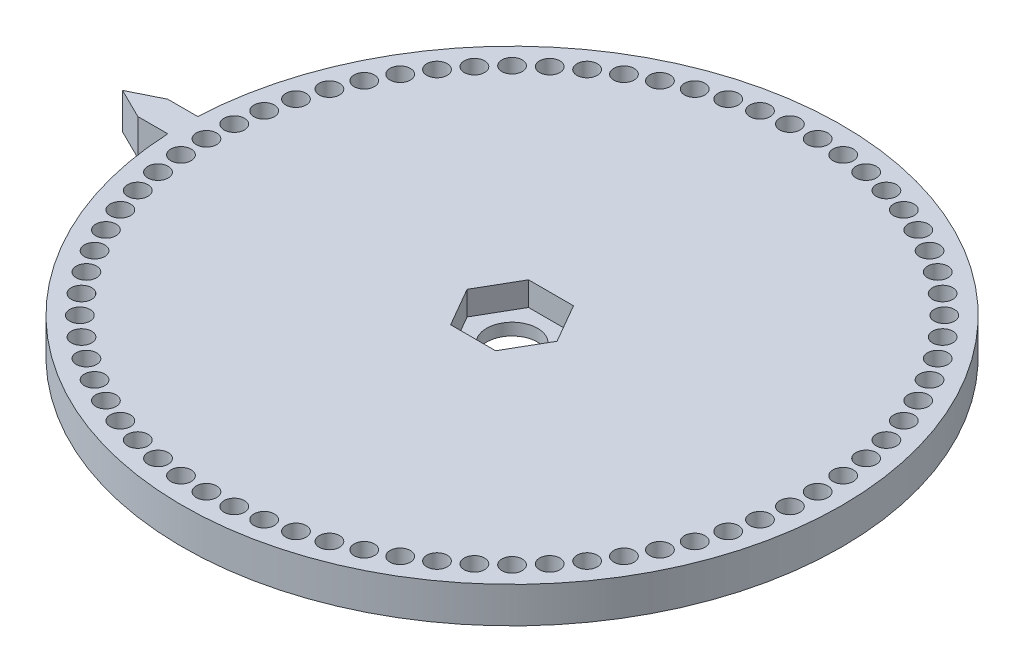
from build123d import *

# Parameters (mm, degrees)
SKETCH1_R           = 55
BOSS_EXTRUDE1_DEPTH = 6
CUT_EXTRUDE1_DEPTH  = 4
SKETCH3_R           = 1.7
CUT_EXTRUDE2_DEPTH  = 7
CIRPATTERN1_COUNT   = 72
SKETCH4_R           = 4.25
CUT_EXTRUDE3_DEPTH  = 3
BOSS_EXTRUDE2_DEPTH = 6


with BuildPart() as part:
    # Sketch1 → Boss-Extrude1 (new body)
    with BuildSketch(Plane(origin=(0, 0, 0), x_dir=(1, 0, 0), z_dir=(0, 1, 0))):
        Circle(SKETCH1_R)
    extrude(amount=BOSS_EXTRUDE1_DEPTH)

    # Sketch2 → Cut-Extrude1 (cut)
    with BuildSketch(Plane(origin=(0, 6, 0), x_dir=(1, 0, 0), z_dir=(0, 1, 0))):
        Polygon((3.75277675, 6.5), (-3.75277675, 6.5), (-7.505553499, 0), (-3.75277675, -6.5), (3.75277675, -6.5), (7.505553499, 0), align=None)
    extrude(amount=-CUT_EXTRUDE1_DEPTH, mode=Mode.SUBTRACT)

    # Sketch3 → Cut-Extrude2 (cut, through all)
    with BuildSketch(Plane(origin=(0, 6, 0), x_dir=(1, 0, 0), z_dir=(0, 1, 0))):
        with Locations((0, 51)):
            Circle(SKETCH3_R)
    cut_extrude2 = extrude(amount=-CUT_EXTRUDE2_DEPTH, mode=Mode.SUBTRACT)

    # CirPattern1: Cut-Extrude2 ×72 about axis
    cirpattern1_axis = Axis((0, 0, 0), (0, 1, 0))
    for i in range(1, CIRPATTERN1_COUNT):
        add(cut_extrude2.rotate(cirpattern1_axis, i * 360 / CIRPATTERN1_COUNT), mode=Mode.SUBTRACT)

    # Sketch4 → Cut-Extrude3 (cut, through all)
    with BuildSketch(Plane(origin=(0, 2, 0), x_dir=(1, 0, 0), z_dir=(0, 1, 0))):
        Circle(SKETCH4_R)
    extrude(amount=-CUT_EXTRUDE3_DEPTH, mode=Mode.SUBTRACT)

    # Sketch5 → Boss-Extrude2 (add)
    with BuildSketch(Plane(origin=(0, 6, 0), x_dir=(1, 0, 0), z_dir=(0, 1, 0))):
        Polygon((-59.94315244, 2.5), (-65, 0), (-59.94315244, -2.5), (-54.94315244, -2.5), (-54.94315244, 2.5), align=None)
    extrude(amount=-BOSS_EXTRUDE2_DEPTH)


solid = part.part
